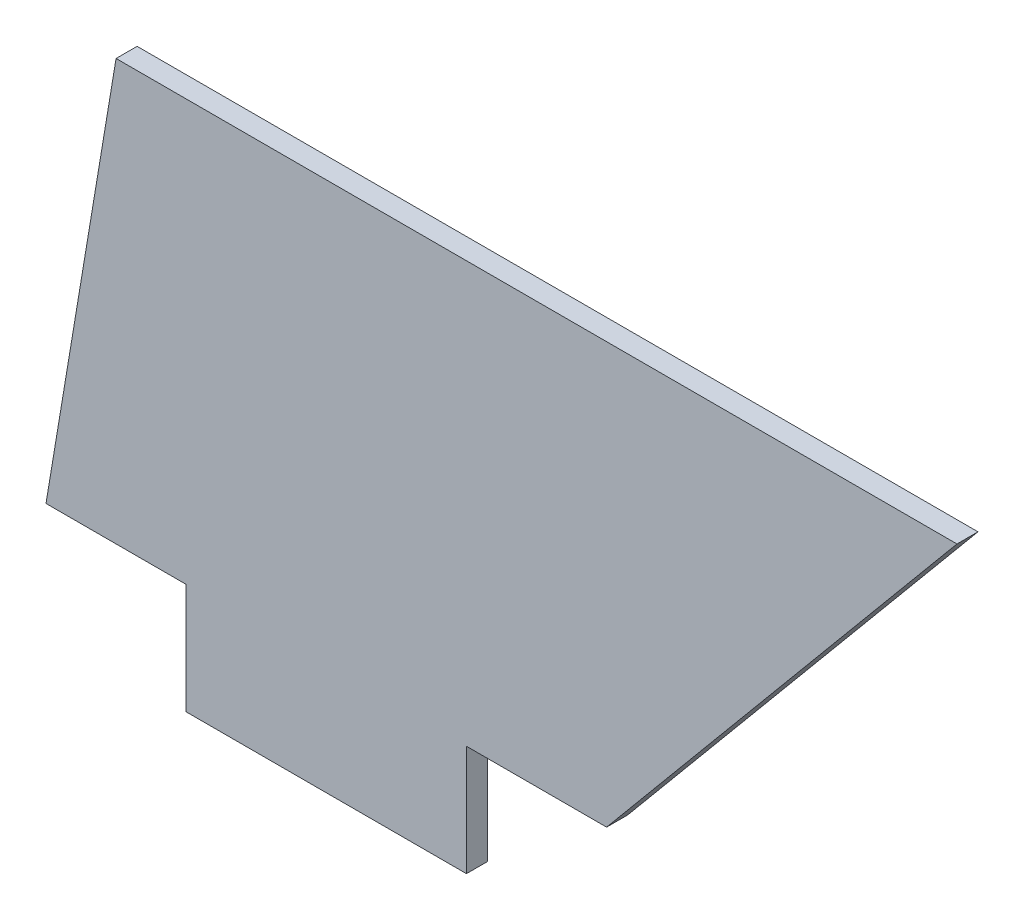
from build123d import *

# Parameters (mm, degrees)
BOSS_EXTRUDE1_DEPTH = 1.5


with BuildPart() as part:
    # Sketch1 → Boss-Extrude1 (new body)
    with BuildSketch(Plane.XY):
        Polygon((0, 0), (10, 0), (10, -7.875), (30, -7.875), (30, 0), (40, 0), (65, 30), (5, 30), align=None)
    extrude(amount=BOSS_EXTRUDE1_DEPTH)


solid = part.part
